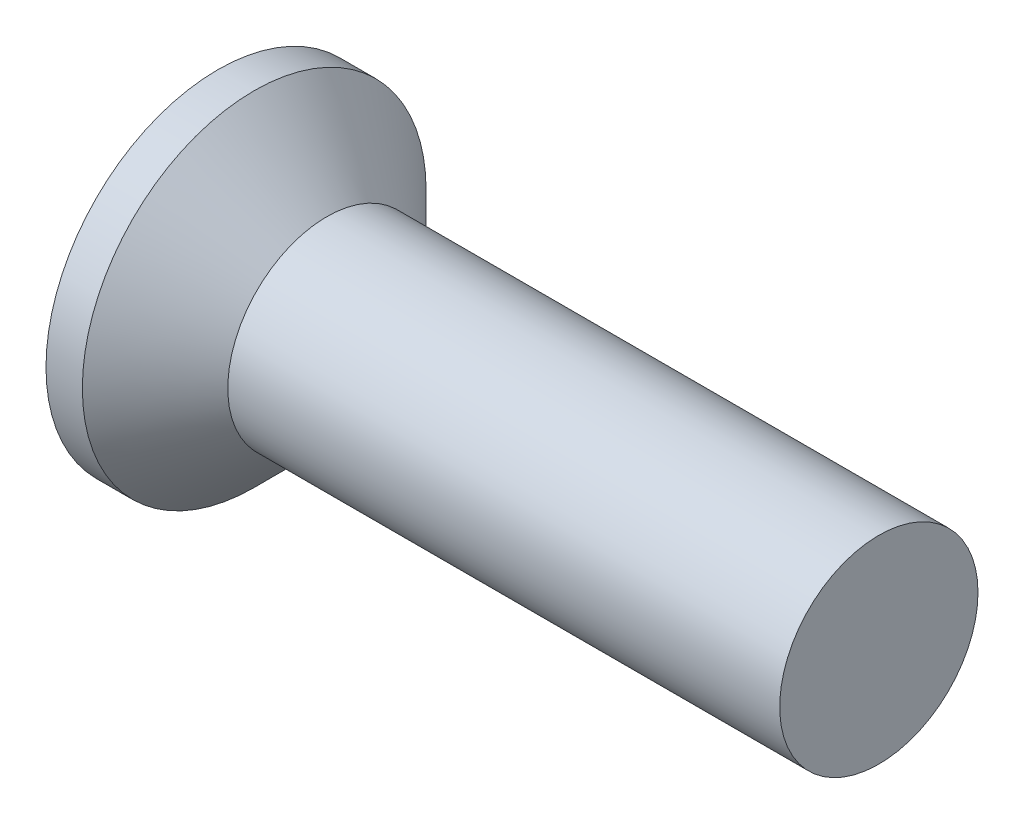
from build123d import *

# Parameters (mm, degrees)
CROSSRECESS_DEPTH = 0.825
DRAFT9_ANGLE      = 30
FILLET5_R         = 0.3


with BuildPart() as part:
    # Sketch1 → Base (revolve)
    with BuildSketch(Plane.XY):
        Polygon((10, 1.5), (2.65, 1.5), (1.65, 1.5), (0.55, 2.6), (0, 2.6), (0, 0), (10, 0), align=None)
    revolve(axis=Axis((4.515812911, 0, 0), (-1, 0, 0)))

    # Sketch6 → CrossRecess (cut)
    with BuildSketch(Plane(origin=(0, 0, 0), x_dir=(0, 0, -1), z_dir=(1, 0, 0))):
        Polygon((0.32, 0.32), (0.32, 1.6), (-0.32, 1.6), (-0.32, 0.32), (-1.6, 0.32), (-1.6, -0.32), (-0.32, -0.32), (-0.32, -1.6), (0.32, -1.6), (0.32, -0.32), (1.6, -0.32), (1.6, 0.32), align=None)
    extrude(amount=CROSSRECESS_DEPTH, mode=Mode.SUBTRACT)

    # Draft9
    draft9_faces = [part.faces().sort_by_distance(p)[0] for p in [
        (0.4125, 1.6, 0),
        (0.4125, 0, 1.6),
        (0.4125, -1.6, 0),
        (0.4125, 0, -1.6),
    ]]
    draft(draft9_faces, Plane(origin=(0, 2.6, 0), x_dir=(0, 0, -1), z_dir=(-1, 0, 0)), DRAFT9_ANGLE)

    # Fillet5
    fillet5_edges = [part.edges().sort_by_distance(p)[0] for p in [
        (0.4125, 0.32, 0.32),
        (0.4125, -0.32, 0.32),
        (0.4125, -0.32, -0.32),
        (0.4125, 0.32, -0.32),
    ]]
    fillet(fillet5_edges, radius=FILLET5_R)


solid = part.part
